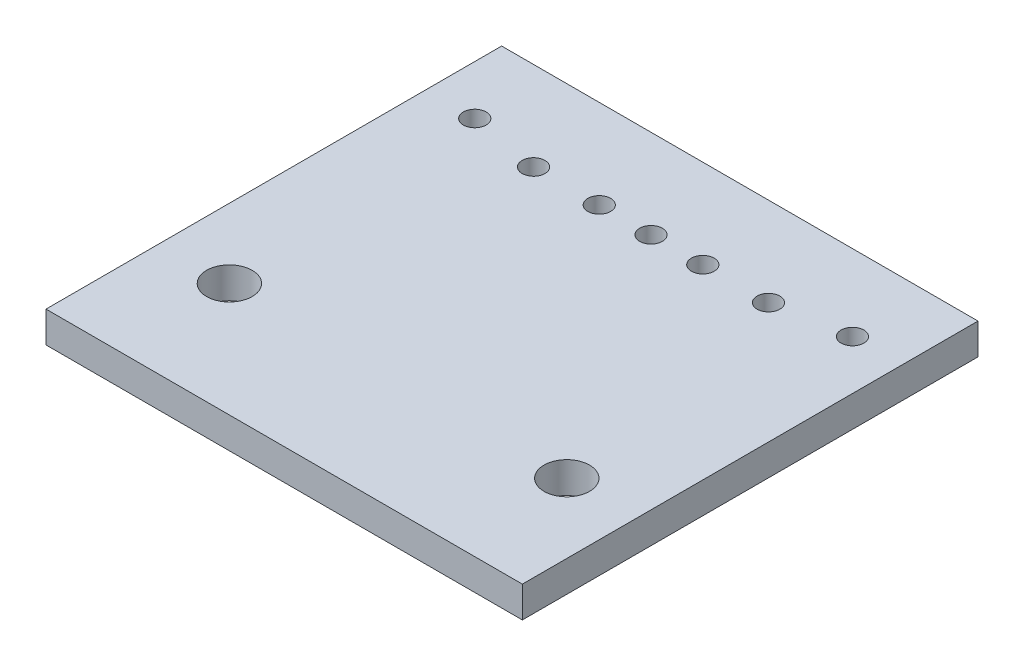
from build123d import *

# Parameters (mm, degrees)
SKETCH1_W           = 23
SKETCH1_H           = 22
BOSS_EXTRUDE1_DEPTH = 1.5
SKETCH3_R           = 1.1
SKETCH3_R_2         = 0.55
CUT_EXTRUDE1_DEPTH  = 2.5


with BuildPart() as part:
    # Sketch1 → Boss-Extrude1 (new body)
    with BuildSketch(Plane(origin=(0, 0, 0), x_dir=(1, 0, 0), z_dir=(0, 1, 0))):
        Rectangle(SKETCH1_W, SKETCH1_H)
    extrude(amount=BOSS_EXTRUDE1_DEPTH)

    # Sketch3 → Cut-Extrude1 (cut, through all)
    with BuildSketch(Plane(origin=(0, 1.5, 0), x_dir=(1, 0, 0), z_dir=(0, 1, 0))):
        with Locations((-8.145066425, -5.5)):
            Circle(SKETCH3_R)
        with Locations((-9.118479993, 7.320274236)):
            Circle(SKETCH3_R_2)
        with Locations((-5.671652858, 6.712505614)):
            Circle(SKETCH3_R_2)
        with Locations((-2.499970841, 6.712413139)):
            Circle(SKETCH3_R_2)
        with Locations((2.9158e-05, 6.712340249)):
            Circle(SKETCH3_R_2)
        with Locations((2.500029157, 6.712267358)):
            Circle(SKETCH3_R_2)
        with Locations((5.671711174, 6.712174883)):
            Circle(SKETCH3_R_2)
        with Locations((9.118492048, 7.320205417)):
            Circle(SKETCH3_R_2)
        with Locations((8.145066425, -5.5)):
            Circle(SKETCH3_R)
    extrude(amount=-CUT_EXTRUDE1_DEPTH, mode=Mode.SUBTRACT)


solid = part.part
